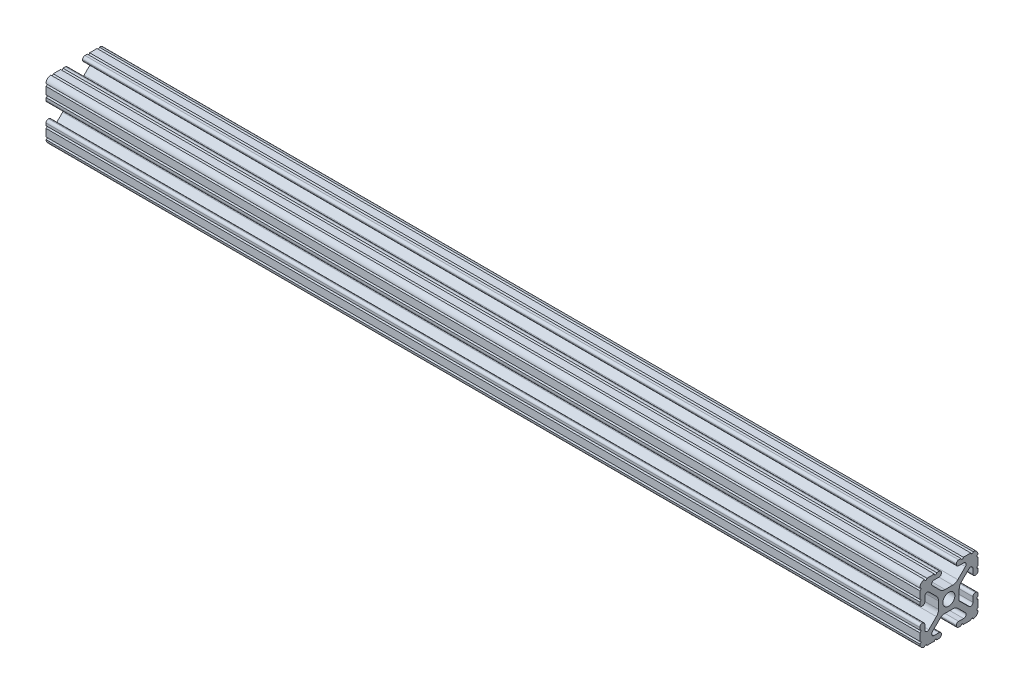
from build123d import *

# Parameters (mm, degrees)
SKETCH1_R           = 2.6035
BOSS_EXTRUDE1_DEPTH = 190.5


with BuildPart() as part:
    # Sketch1 → Boss-Extrude1 (new body, symmetric)
    with BuildSketch(Plane(origin=(0, 0, 0), x_dir=(0, 0, -1), z_dir=(1, 0, 0))):
        with BuildLine():
            Line((6.333126718, -12.7), (9.550443118, -12.7))
            ThreePointArc((9.550443118, -12.7), (10.058366869, -12.192000006), (10.566443095, -12.699847501))
            ThreePointArc((10.566443095, -12.699847501), (12.082537762, -12.08250727), (12.699846982, -10.566399977))
            ThreePointArc((12.699846982, -10.566399977), (12.192000006, -10.058323491), (12.7, -9.5504))
            Line((12.7, -9.5504), (12.7, -6.3330836))
            ThreePointArc((12.7, -6.3330836), (12.192, -5.8250836), (12.7, -5.3170836))
            Line((12.7, -5.3170836), (12.7, -4.287469289))
            ThreePointArc((12.7, -4.287469289), (12.39275138, -3.545705502), (11.650987593, -3.238456882))
            Line((11.650987593, -3.238456882), (11.539212407, -3.238456882))
            ThreePointArc((11.539212407, -3.238456882), (10.79744862, -3.545705502), (10.4902, -4.287469289))
            Line((10.4902, -4.287469289), (10.4902, -6.402089023))
            ThreePointArc((10.4902, -6.402089023), (9.856505071, -7.351067942), (8.737131347, -7.129408934))
            Line((8.737131347, -7.129408934), (4.5085, -2.9104418))
            Line((4.5085, -2.9104418), (4.5085, 1.593185507))
            ThreePointArc((4.5085, 1.593185507), (4.750877967, 2.809883091), (5.441005833, 3.840816462))
            Line((5.441005833, 3.840816462), (8.737131347, 7.129408934))
            ThreePointArc((8.737131347, 7.129408934), (9.856505071, 7.351067942), (10.4902, 6.402089023))
            Line((10.4902, 6.402089023), (10.4902, 4.287469289))
            ThreePointArc((10.4902, 4.287469289), (10.79744862, 3.545705502), (11.539212407, 3.238456882))
            Line((11.539212407, 3.238456882), (11.650987593, 3.238456882))
            ThreePointArc((11.650987593, 3.238456882), (12.39275138, 3.545705502), (12.7, 4.287469289))
            Line((12.7, 4.287469289), (12.7, 5.3170836))
            ThreePointArc((12.7, 5.3170836), (12.192, 5.8250836), (12.7, 6.3330836))
            Line((12.7, 6.3330836), (12.7, 9.5504))
            ThreePointArc((12.7, 9.5504), (12.192000006, 10.058323491), (12.699846982, 10.566399977))
            ThreePointArc((12.699846982, 10.566399977), (12.082537762, 12.08250727), (10.566443095, 12.699847501))
            ThreePointArc((10.566443095, 12.699847501), (10.058366869, 12.192000006), (9.550443118, 12.7))
            Line((9.550443118, 12.7), (6.333126718, 12.7))
            ThreePointArc((6.333126718, 12.7), (5.825126718, 12.192), (5.317126718, 12.7))
            Line((5.317126718, 12.7), (4.287512407, 12.7))
            ThreePointArc((4.287512407, 12.7), (3.54574862, 12.39275138), (3.2385, 11.650987593))
            Line((3.2385, 11.650987593), (3.2385, 11.539212407))
            ThreePointArc((3.2385, 11.539212407), (3.54574862, 10.79744862), (4.287512407, 10.4902))
            Line((4.287512407, 10.4902), (6.476788598, 10.4902))
            ThreePointArc((6.476788598, 10.4902), (7.432222385, 9.85140422), (7.207036008, 8.724370562))
            Line((7.207036008, 8.724370562), (3.898272566, 5.423169045))
            ThreePointArc((3.898272566, 5.423169045), (2.869120213, 4.736787962), (1.655778399, 4.4958))
            Line((1.655778399, 4.4958), (-1.655778399, 4.4958))
            ThreePointArc((-1.655778399, 4.4958), (-2.869120213, 4.736787962), (-3.898272566, 5.423169045))
            Line((-3.898272566, 5.423169045), (-7.207036008, 8.724370562))
            ThreePointArc((-7.207036008, 8.724370562), (-7.432222385, 9.85140422), (-6.476788598, 10.4902))
            Line((-6.476788598, 10.4902), (-4.287512407, 10.4902))
            ThreePointArc((-4.287512407, 10.4902), (-3.54574862, 10.79744862), (-3.2385, 11.539212407))
            Line((-3.2385, 11.539212407), (-3.2385, 11.650987593))
            ThreePointArc((-3.2385, 11.650987593), (-3.54574862, 12.39275138), (-4.287512407, 12.7))
            Line((-4.287512407, 12.7), (-5.317126718, 12.7))
            ThreePointArc((-5.317126718, 12.7), (-5.825126718, 12.192), (-6.333126718, 12.7))
            Line((-6.333126718, 12.7), (-9.550443118, 12.7))
            ThreePointArc((-9.550443118, 12.7), (-10.058366869, 12.192000006), (-10.566443095, 12.699847501))
            ThreePointArc((-10.566443095, 12.699847501), (-12.082537762, 12.08250727), (-12.699846982, 10.566399977))
            ThreePointArc((-12.699846982, 10.566399977), (-12.192000006, 10.058323491), (-12.7, 9.5504))
            Line((-12.7, 9.5504), (-12.7, 6.3330836))
            ThreePointArc((-12.7, 6.3330836), (-12.192, 5.8250836), (-12.7, 5.3170836))
            Line((-12.7, 5.3170836), (-12.7, 4.287469289))
            ThreePointArc((-12.7, 4.287469289), (-12.39275138, 3.545705502), (-11.650987593, 3.238456882))
            Line((-11.650987593, 3.238456882), (-11.539212407, 3.238456882))
            ThreePointArc((-11.539212407, 3.238456882), (-10.79744862, 3.545705502), (-10.4902, 4.287469289))
            Line((-10.4902, 4.287469289), (-10.4902, 6.402089023))
            ThreePointArc((-10.4902, 6.402089023), (-9.856505071, 7.351067942), (-8.737131347, 7.129408934))
            Line((-8.737131347, 7.129408934), (-5.441005833, 3.840816462))
            ThreePointArc((-5.441005833, 3.840816462), (-4.750877967, 2.809883091), (-4.5085, 1.593185507))
            Line((-4.5085, 1.593185507), (-4.5085, -1.593185507))
            ThreePointArc((-4.5085, -1.593185507), (-4.750877967, -2.809883091), (-5.441005833, -3.840816462))
            Line((-5.441005833, -3.840816462), (-8.737131347, -7.129408934))
            ThreePointArc((-8.737131347, -7.129408934), (-9.856505071, -7.351067942), (-10.4902, -6.402089023))
            Line((-10.4902, -6.402089023), (-10.4902, -4.287469289))
            ThreePointArc((-10.4902, -4.287469289), (-10.79744862, -3.545705502), (-11.539212407, -3.238456882))
            Line((-11.539212407, -3.238456882), (-11.650987593, -3.238456882))
            ThreePointArc((-11.650987593, -3.238456882), (-12.39275138, -3.545705502), (-12.7, -4.287469289))
            Line((-12.7, -4.287469289), (-12.7, -5.3170836))
            ThreePointArc((-12.7, -5.3170836), (-12.192, -5.8250836), (-12.7, -6.3330836))
            Line((-12.7, -6.3330836), (-12.7, -9.5504))
            ThreePointArc((-12.7, -9.5504), (-12.192000006, -10.058323491), (-12.699846982, -10.566399977))
            ThreePointArc((-12.699846982, -10.566399977), (-12.082537762, -12.08250727), (-10.566443095, -12.699847501))
            ThreePointArc((-10.566443095, -12.699847501), (-10.058366869, -12.192000006), (-9.550443118, -12.7))
            Line((-9.550443118, -12.7), (-6.333126718, -12.7))
            ThreePointArc((-6.333126718, -12.7), (-5.825126718, -12.192), (-5.317126718, -12.7))
            Line((-5.317126718, -12.7), (-4.287512407, -12.7))
            ThreePointArc((-4.287512407, -12.7), (-3.54574862, -12.39275138), (-3.2385, -11.650987593))
            Line((-3.2385, -11.650987593), (-3.2385, -11.539212407))
            ThreePointArc((-3.2385, -11.539212407), (-3.54574862, -10.79744862), (-4.287512407, -10.4902))
            Line((-4.287512407, -10.4902), (-6.416408329, -10.4902))
            ThreePointArc((-6.416408329, -10.4902), (-7.41473083, -9.822813117), (-7.179650497, -8.645192506))
            Line((-7.179650497, -8.645192506), (-3.952270251, -5.423690499))
            ThreePointArc((-3.952270251, -5.423690499), (-2.922936451, -4.736929036), (-1.709253557, -4.4958))
            Line((-1.709253557, -4.4958), (1.709253557, -4.4958))
            ThreePointArc((1.709253557, -4.4958), (2.922936451, -4.736929036), (3.952270251, -5.423690499))
            Line((3.952270251, -5.423690499), (7.179650497, -8.645192506))
            ThreePointArc((7.179650497, -8.645192506), (7.41473083, -9.822813117), (6.416408329, -10.4902))
            Line((6.416408329, -10.4902), (4.287512407, -10.4902))
            ThreePointArc((4.287512407, -10.4902), (3.54574862, -10.79744862), (3.2385, -11.539212407))
            Line((3.2385, -11.539212407), (3.2385, -11.650987593))
            ThreePointArc((3.2385, -11.650987593), (3.54574862, -12.39275138), (4.287512407, -12.7))
            Line((4.287512407, -12.7), (5.317126718, -12.7))
            ThreePointArc((5.317126718, -12.7), (5.825126718, -12.192), (6.333126718, -12.7))
        make_face()
        Circle(SKETCH1_R, mode=Mode.SUBTRACT)
    extrude(amount=BOSS_EXTRUDE1_DEPTH, both=True)


solid = part.part
